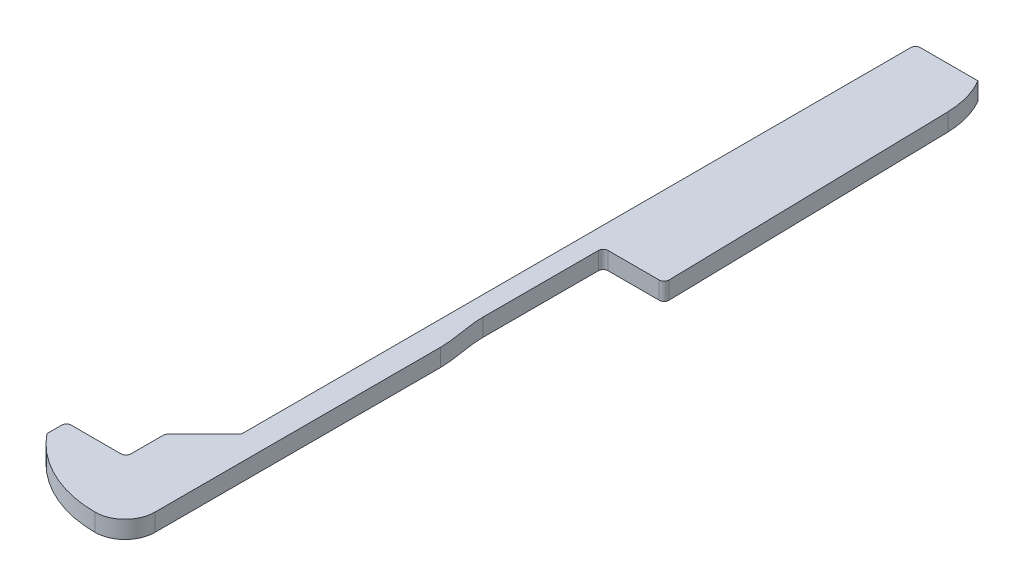
from build123d import *

# Parameters (mm, degrees)
BOSS_EXTRUDE1_DEPTH = 1.8
FILLET2_R           = 0.5


with BuildPart() as part:
    # Sketch1 → Boss-Extrude1 (new body)
    with BuildSketch(Plane(origin=(0, 0, 0), x_dir=(1, 0, 0), z_dir=(0, 1, 0))):
        with BuildLine():
            Line((0, 4.5), (0, 6.5))
            Line((0, 6.5), (6.1, 6.5))
            Line((6.1, 6.5), (6.1, 10.5))
            Line((6.1, 10.5), (10, 14.4))
            Line((10, 14.4), (10, 83.5))
            Line((10, 83.5), (16.4, 83.5))
            ThreePointArc((16.4, 83.5), (17.2719581, 81.425344658), (17.601960582, 79.199226044))
            Line((17.601960582, 79.199226044), (18.25, 49.5))
            Line((18.25, 49.5), (12, 49.5))
            Line((12, 49.5), (12, 37.18))
            add(Edge.make_bspline(
                [(12.5, 32.33), (12.5, 33.972282338), (12, 35.554764974), (12, 37.18)],
                knots=[0, 0, 0, 0, 1, 1, 1, 1], degree=3))
            Line((12.5, 32.33), (12.5, 3.07))
            ThreePointArc((12.5, 3.07), (11.600817818, 0.899182182), (9.43, 0))
            ThreePointArc((9.43, 0), (4.205660329, 1.182650422), (0, 4.5))
        make_face()
    extrude(amount=BOSS_EXTRUDE1_DEPTH)

    # Fillet2
    fillet2_edges = [part.edges().sort_by_distance(p)[0] for p in [
        (0, 0.9, -6.5),
        (6.1, 0.9, -6.5),
        (6.1, 0.9, -10.5),
        (10, 0.9, -14.4),
        (10, 0.9, -83.5),
        (18.25, 0.9, -49.5),
        (12, 0.9, -49.5),
    ]]
    fillet(fillet2_edges, radius=FILLET2_R)


solid = part.part
